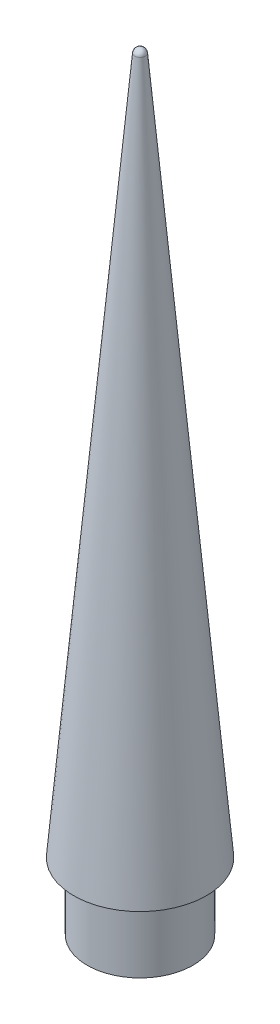
from build123d import *

# Parameters (mm, degrees)
SKETCH2_R                 = 10.033
BOSS_EXTRUDE1_DEPTH       = 12.7
M3X0_5_TAPPED_HOLE1_D     = 2.5
M3X0_5_TAPPED_HOLE1_DEPTH = 10.16
M3X0_5_TAPPED_HOLE1_TIP   = 0.751075774


with BuildPart() as part:
    # Sketch1 → Revolve2 (revolve)
    with BuildSketch(Plane.XY):
        with BuildLine():
            Line((0, 0), (0, 133.068754945))
            ThreePointArc((0, 133.068754945), (0.686399651, 132.801828719), (1.012133813, 132.14130518))
            Line((1.012133813, 132.14130518), (12.573, 0))
            Line((12.573, 0), (0, 0))
        make_face()
    revolve(axis=Axis((0, 0, 0), (0, 1, 0)))

    # Sketch2 → Boss-Extrude1 (add)
    with BuildSketch(Plane.XZ):
        Circle(SKETCH2_R)
    extrude(amount=BOSS_EXTRUDE1_DEPTH)

    # M3x0.5 Tapped Hole1
    with Locations(Plane.XZ.offset(12.7)):
        with Locations((0, 0)):
            Hole(M3X0_5_TAPPED_HOLE1_D / 2, depth=M3X0_5_TAPPED_HOLE1_DEPTH)
            with Locations((0, 0, -(M3X0_5_TAPPED_HOLE1_DEPTH + M3X0_5_TAPPED_HOLE1_TIP / 2))):  # 118° drill point
                Cone(0, M3X0_5_TAPPED_HOLE1_D / 2, M3X0_5_TAPPED_HOLE1_TIP, mode=Mode.SUBTRACT)


solid = part.part
